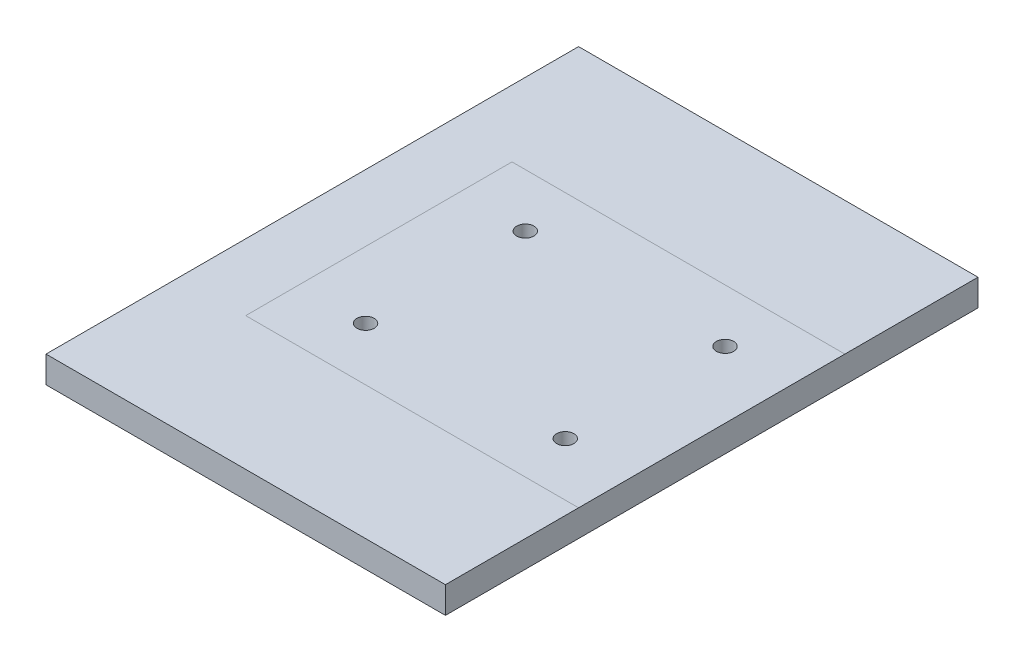
from build123d import *

# Parameters (mm, degrees)
SKETCH1_W           = 300
SKETCH1_H           = 400
SUPPORT_PLATE_DEPTH = 20
SKETCH2_R           = 6.5
BOLT_HOLES_DEPTH    = 21


with BuildPart() as part:
    # Sketch1 → Support Plate (new body)
    with BuildSketch(Plane(origin=(0, 0, 0), x_dir=(1, 0, 0), z_dir=(0, 1, 0))):
        Rectangle(SKETCH1_W, SKETCH1_H)
    extrude(amount=-SUPPORT_PLATE_DEPTH)

    # Sketch2 → Bolt Holes (cut, through all)
    with BuildSketch(Plane(origin=(0, 0, 0), x_dir=(-1, 0, 0), z_dir=(0, 1, 0))):
        with Locations((-100, -60)):
            Circle(SKETCH2_R)
        with Locations((50, -60)):
            Circle(SKETCH2_R)
        with Locations((50, 60)):
            Circle(SKETCH2_R)
        with Locations((-100, 60)):
            Circle(SKETCH2_R)
    extrude(amount=-BOLT_HOLES_DEPTH, mode=Mode.SUBTRACT)


solid = part.part
